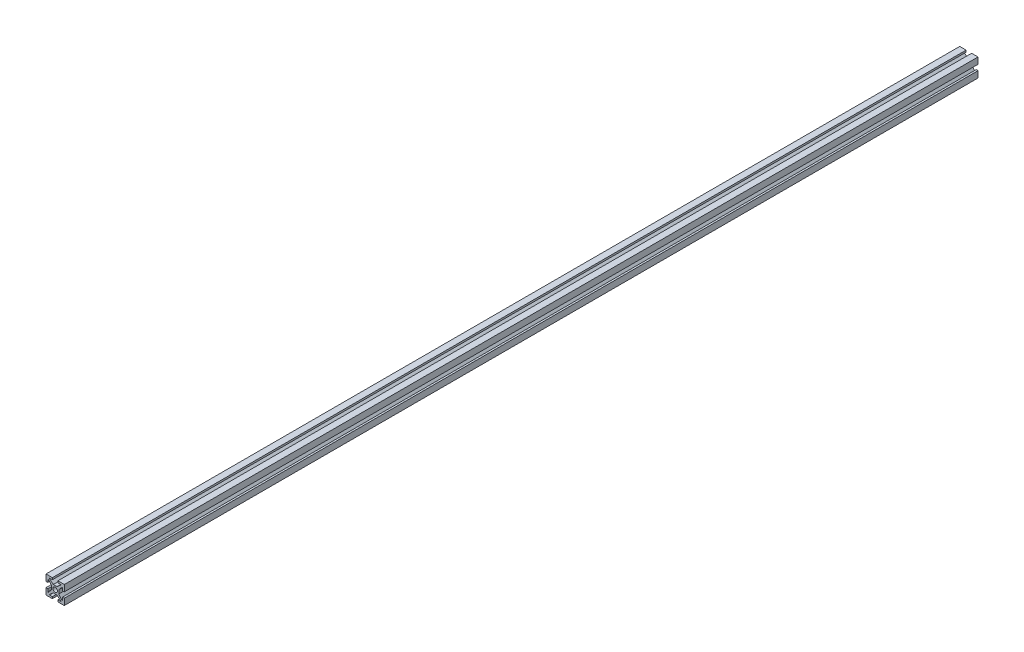
from build123d import *

# Parameters (mm, degrees)
BOSS_EXTRU_1_DEPTH           = 500
R_P_TITION_CIRCULAIRE1_COUNT = 4


with BuildPart() as part:
    # Esquisse1 → Boss.-Extru.1 (new body)
    with BuildSketch(Plane.XY):
        with BuildLine():
            Line((0, 2), (0, 1.25))
            ThreePointArc((0, 1.25), (-0.883883476, 0.883883476), (-1.25, 0))
            Line((-1.25, 0), (-2, 0))
            Line((-2, 0), (-2, 1))
            Line((-2, 1), (-3.735093334, 3.067803714))
            ThreePointArc((-3.735093334, 3.067803714), (-3.901303021, 3.112339465), (-4, 2.971385572))
            Line((-4, 2.971385572), (-4, 1.5))
            Line((-4, 1.5), (-5, 1.5))
            Line((-5, 1.5), (-5, 5))
            Line((-5, 5), (-1.5, 5))
            Line((-1.5, 5), (-1.5, 4))
            Line((-1.5, 4), (-2.971385572, 4))
            ThreePointArc((-2.971385572, 4), (-3.112339465, 3.901303021), (-3.067803714, 3.735093334))
            Line((-3.067803714, 3.735093334), (-1, 2))
            Line((-1, 2), (0, 2))
        make_face()
    boss_extru_1 = extrude(amount=BOSS_EXTRU_1_DEPTH)

    # Répétition circulaire1: Boss.-Extru.1 ×4 about axis
    r_p_tition_circulaire1_axis = Axis((0, 0, 105), (0, 0, -1))
    for i in range(1, R_P_TITION_CIRCULAIRE1_COUNT):
        add(boss_extru_1.rotate(r_p_tition_circulaire1_axis, i * 360 / R_P_TITION_CIRCULAIRE1_COUNT))


solid = part.part
